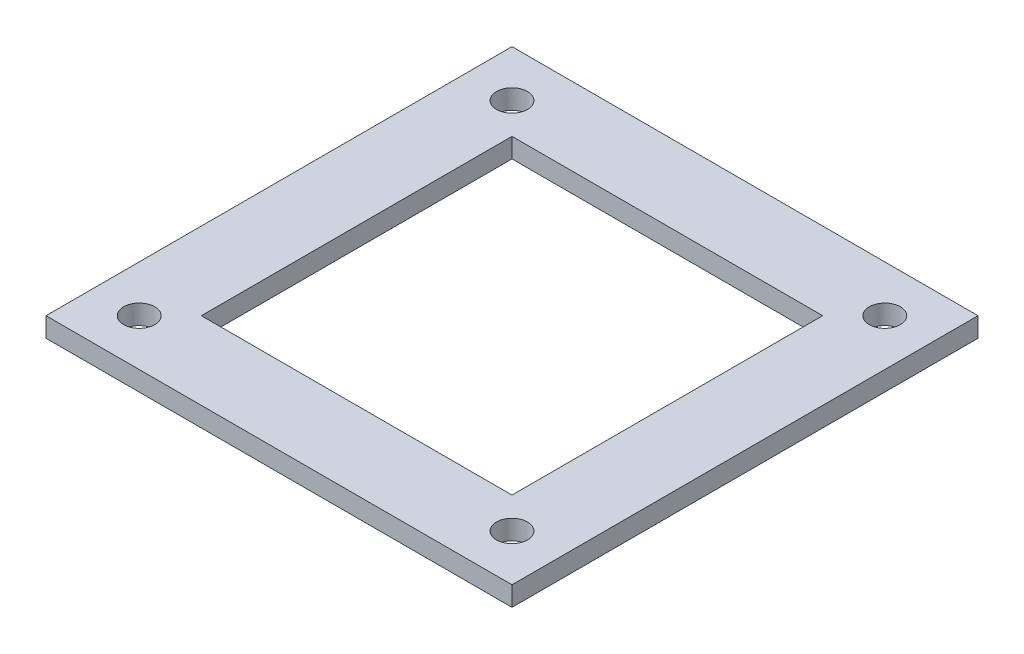
from build123d import *

# Parameters (mm, degrees)
SKETCH1_W           = 95.25
SKETCH1_H           = 95.25
SKETCH1_R           = 3.175
SKETCH1_W_2         = 63.5
SKETCH1_H_2         = 63.5
BOSS_EXTRUDE1_DEPTH = 4


with BuildPart() as part:
    # Sketch1 → Boss-Extrude1 (new body)
    with BuildSketch(Plane(origin=(0, 0, 0), x_dir=(1, 0, 0), z_dir=(0, 1, 0))):
        Rectangle(SKETCH1_W, SKETCH1_H)
        with Locations((-38.1, 38.1)):
            Circle(SKETCH1_R, mode=Mode.SUBTRACT)
        with Locations((38.1, 38.1)):
            Circle(SKETCH1_R, mode=Mode.SUBTRACT)
        with Locations((38.1, -38.1)):
            Circle(SKETCH1_R, mode=Mode.SUBTRACT)
        with Locations((-38.1, -38.1)):
            Circle(SKETCH1_R, mode=Mode.SUBTRACT)
        Rectangle(SKETCH1_W_2, SKETCH1_H_2, mode=Mode.SUBTRACT)
    extrude(amount=BOSS_EXTRUDE1_DEPTH)


solid = part.part
